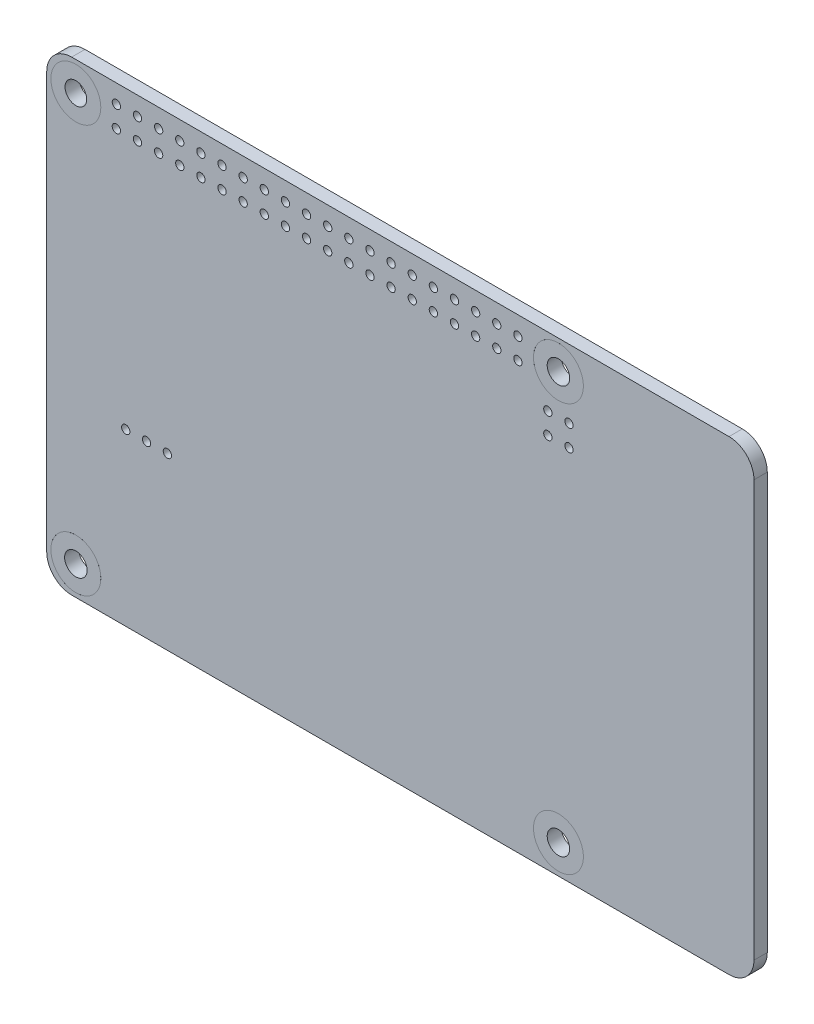
from build123d import *

# Parameters (mm, degrees)
BOSS_EXTRUDE1_DEPTH   = 1.6
SKETCH3_R             = 3
CUT_EXTRUDE1_DEPTH    = 2.6
SKETCH4_R             = 3
SKETCH4_R_2           = 1.35
BOSS_EXTRUDE2_DEPTH   = 1.7
BOSS_EXTRUDE2_2_DEPTH = 1.7
BOSS_EXTRUDE2_3_DEPTH = 1.7
SKETCH4_R_3           = 1.3
BOSS_EXTRUDE2_4_DEPTH = 1.7
SKETCH5_R             = 0.5
CUT_EXTRUDE2_DEPTH    = 2.7
SKETCH6_R             = 0.5
CUT_EXTRUDE3_DEPTH    = 2.7
SKETCH7_R             = 0.5
CUT_EXTRUDE4_DEPTH    = 2.7


with BuildPart() as part:
    # Sketch1 → Boss-Extrude1 (new body)
    with BuildSketch(Plane.XY):
        with BuildLine():
            Line((-39.5, -28), (39.5, -28))
            ThreePointArc((39.5, -28), (41.621320344, -27.121320344), (42.5, -25))
            Line((42.5, -25), (42.5, 25))
            ThreePointArc((42.5, 25), (41.621320344, 27.121320344), (39.5, 28))
            Line((39.5, 28), (-39.5, 28))
            ThreePointArc((-39.5, 28), (-41.621320344, 27.121320344), (-42.5, 25))
            Line((-42.5, 25), (-42.5, -25))
            ThreePointArc((-42.5, -25), (-41.621320344, -27.121320344), (-39.5, -28))
        make_face()
    extrude(amount=BOSS_EXTRUDE1_DEPTH)

    # Sketch3 → Cut-Extrude1 (cut, through all)
    with BuildSketch(Plane.XY.offset(1.6)):
        with Locations((-39, 24.5)):
            Circle(SKETCH3_R)
        with Locations((-39, -24.5)):
            Circle(SKETCH3_R)
        with Locations((19, -24.5)):
            Circle(SKETCH3_R)
        with Locations((19, 24.5)):
            Circle(SKETCH3_R)
    extrude(amount=-CUT_EXTRUDE1_DEPTH, mode=Mode.SUBTRACT)

    # Sketch5 → Cut-Extrude2 (cut, through all)
    with BuildSketch(Plane.XY.offset(1.6)):
        with Locations((-33, -7.5)):
            Circle(SKETCH5_R)
        with Locations((-30.5, -7.5)):
            Circle(SKETCH5_R)
        with Locations((-28, -7.5)):
            Circle(SKETCH5_R)
    extrude(amount=-CUT_EXTRUDE2_DEPTH, mode=Mode.SUBTRACT)

    # Sketch6 → Cut-Extrude3 (cut, through all)
    with BuildSketch(Plane.XY.offset(1.6)):
        with Locations((-34.13, 25.77)):
            Circle(SKETCH6_R)
        with Locations((-34.13, 23.23)):
            Circle(SKETCH6_R)
        with Locations((-31.59, 25.77)):
            Circle(SKETCH6_R)
        with Locations((-31.59, 23.23)):
            Circle(SKETCH6_R)
        with Locations((-29.05, 25.77)):
            Circle(SKETCH6_R)
        with Locations((-29.05, 23.23)):
            Circle(SKETCH6_R)
        with Locations((-26.51, 25.77)):
            Circle(SKETCH6_R)
        with Locations((-26.51, 23.23)):
            Circle(SKETCH6_R)
        with Locations((-23.97, 25.77)):
            Circle(SKETCH6_R)
        with Locations((-23.97, 23.23)):
            Circle(SKETCH6_R)
        with Locations((-21.43, 25.77)):
            Circle(SKETCH6_R)
        with Locations((-21.43, 23.23)):
            Circle(SKETCH6_R)
        with Locations((-18.89, 25.77)):
            Circle(SKETCH6_R)
        with Locations((-18.89, 23.23)):
            Circle(SKETCH6_R)
        with Locations((-16.35, 25.77)):
            Circle(SKETCH6_R)
        with Locations((-16.35, 23.23)):
            Circle(SKETCH6_R)
        with Locations((-13.81, 25.77)):
            Circle(SKETCH6_R)
        with Locations((-13.81, 23.23)):
            Circle(SKETCH6_R)
        with Locations((-11.27, 25.77)):
            Circle(SKETCH6_R)
        with Locations((-11.27, 23.23)):
            Circle(SKETCH6_R)
        with Locations((-8.73, 25.77)):
            Circle(SKETCH6_R)
        with Locations((-8.73, 23.23)):
            Circle(SKETCH6_R)
        with Locations((-6.19, 25.77)):
            Circle(SKETCH6_R)
        with Locations((-6.19, 23.23)):
            Circle(SKETCH6_R)
        with Locations((-3.65, 25.77)):
            Circle(SKETCH6_R)
        with Locations((-3.65, 23.23)):
            Circle(SKETCH6_R)
        with Locations((-1.11, 25.77)):
            Circle(SKETCH6_R)
        with Locations((-1.11, 23.23)):
            Circle(SKETCH6_R)
        with Locations((1.43, 25.77)):
            Circle(SKETCH6_R)
        with Locations((1.43, 23.23)):
            Circle(SKETCH6_R)
        with Locations((3.97, 25.77)):
            Circle(SKETCH6_R)
        with Locations((3.97, 23.23)):
            Circle(SKETCH6_R)
        with Locations((6.51, 25.77)):
            Circle(SKETCH6_R)
        with Locations((6.51, 23.23)):
            Circle(SKETCH6_R)
        with Locations((9.05, 25.77)):
            Circle(SKETCH6_R)
        with Locations((9.05, 23.23)):
            Circle(SKETCH6_R)
        with Locations((11.59, 25.77)):
            Circle(SKETCH6_R)
        with Locations((11.59, 23.23)):
            Circle(SKETCH6_R)
        with Locations((14.13, 25.77)):
            Circle(SKETCH6_R)
        with Locations((14.13, 23.23)):
            Circle(SKETCH6_R)
    extrude(amount=-CUT_EXTRUDE3_DEPTH, mode=Mode.SUBTRACT)

    # Sketch7 → Cut-Extrude4 (cut, through all)
    with BuildSketch(Plane.XY.offset(1.6)):
        with Locations((20.27, 19.77)):
            Circle(SKETCH7_R)
        with Locations((17.73, 19.77)):
            Circle(SKETCH7_R)
        with Locations((17.73, 17.23)):
            Circle(SKETCH7_R)
        with Locations((20.27, 17.23)):
            Circle(SKETCH7_R)
    extrude(amount=-CUT_EXTRUDE4_DEPTH, mode=Mode.SUBTRACT)


with BuildPart() as body_2:
    # Sketch4 → Boss-Extrude2 (new body)
    with BuildSketch(Plane.XY.offset(1.6)):
        with Locations((-39, -24.5)):
            Circle(SKETCH4_R)
        with Locations((-39, -24.5)):
            Circle(SKETCH4_R_2, mode=Mode.SUBTRACT)
    extrude(amount=-BOSS_EXTRUDE2_DEPTH)


with BuildPart() as body_3:
    # Sketch4 → Boss-Extrude2 2 (new body)
    with BuildSketch(Plane.XY.offset(1.6)):
        with Locations((19, -24.5)):
            Circle(SKETCH4_R)
        with Locations((19, -24.5)):
            Circle(SKETCH4_R_2, mode=Mode.SUBTRACT)
    extrude(amount=-BOSS_EXTRUDE2_2_DEPTH)


with BuildPart() as body_4:
    # Sketch4 → Boss-Extrude2 3 (new body)
    with BuildSketch(Plane.XY.offset(1.6)):
        with Locations((19, 24.5)):
            Circle(SKETCH4_R)
        with Locations((19, 24.5)):
            Circle(SKETCH4_R_2, mode=Mode.SUBTRACT)
    extrude(amount=-BOSS_EXTRUDE2_3_DEPTH)


with BuildPart() as body_5:
    # Sketch4 → Boss-Extrude2 4 (new body)
    with BuildSketch(Plane.XY.offset(1.6)):
        with Locations((-39, 24.5)):
            Circle(SKETCH4_R)
        with Locations((-39, 24.5)):
            Circle(SKETCH4_R_3, mode=Mode.SUBTRACT)
    extrude(amount=-BOSS_EXTRUDE2_4_DEPTH)


solid = Compound([part.part, body_2.part, body_3.part, body_4.part, body_5.part])
